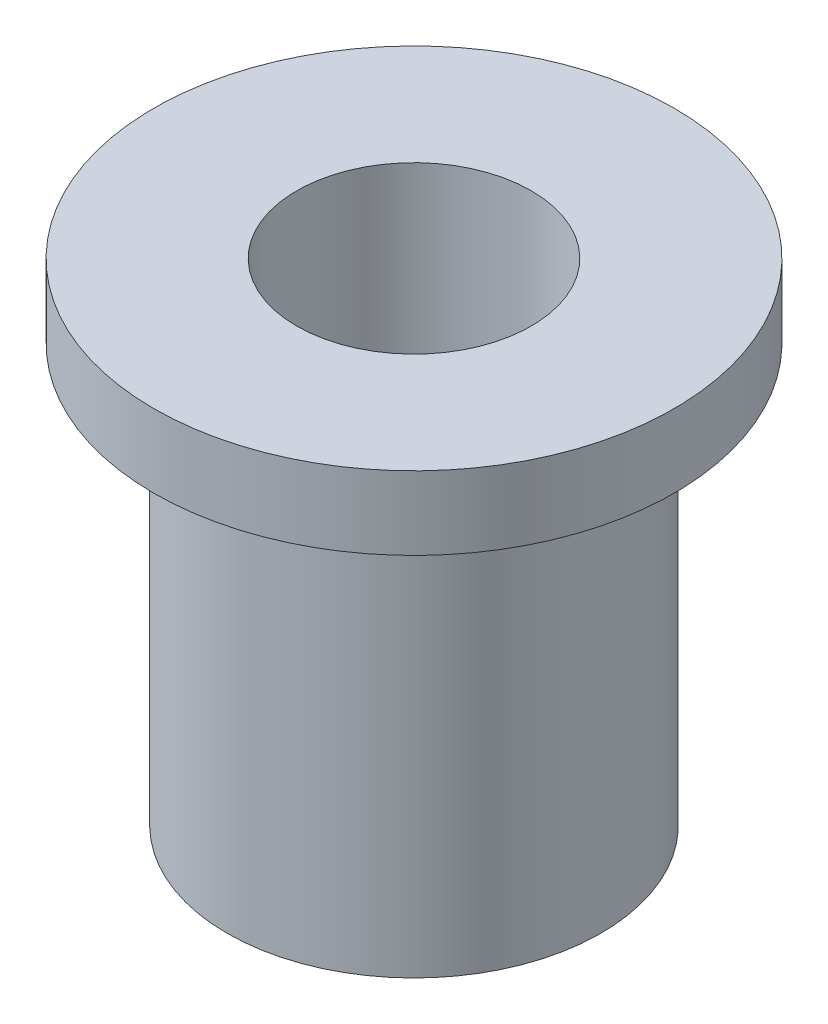
from build123d import *

# Parameters (mm, degrees)
SKETCH1_R           = 2.55
SKETCH1_R_2         = 1.6
BOSS_EXTRUDE1_DEPTH = 6.7
SKETCH2_R           = 3.55
SKETCH2_R_2         = 1.6
BOSS_EXTRUDE2_DEPTH = 1


with BuildPart() as part:
    # Sketch1 → Boss-Extrude1 (new body)
    with BuildSketch(Plane(origin=(0, 0, 0), x_dir=(1, 0, 0), z_dir=(0, 1, 0))):
        Circle(SKETCH1_R)
        Circle(SKETCH1_R_2, mode=Mode.SUBTRACT)
    extrude(amount=BOSS_EXTRUDE1_DEPTH)

    # Sketch2 → Boss-Extrude2 (add)
    with BuildSketch(Plane(origin=(0, 6.7, 0), x_dir=(1, 0, 0), z_dir=(0, 1, 0))):
        Circle(SKETCH2_R)
        Circle(SKETCH2_R_2, mode=Mode.SUBTRACT)
    extrude(amount=-BOSS_EXTRUDE2_DEPTH)


solid = part.part
